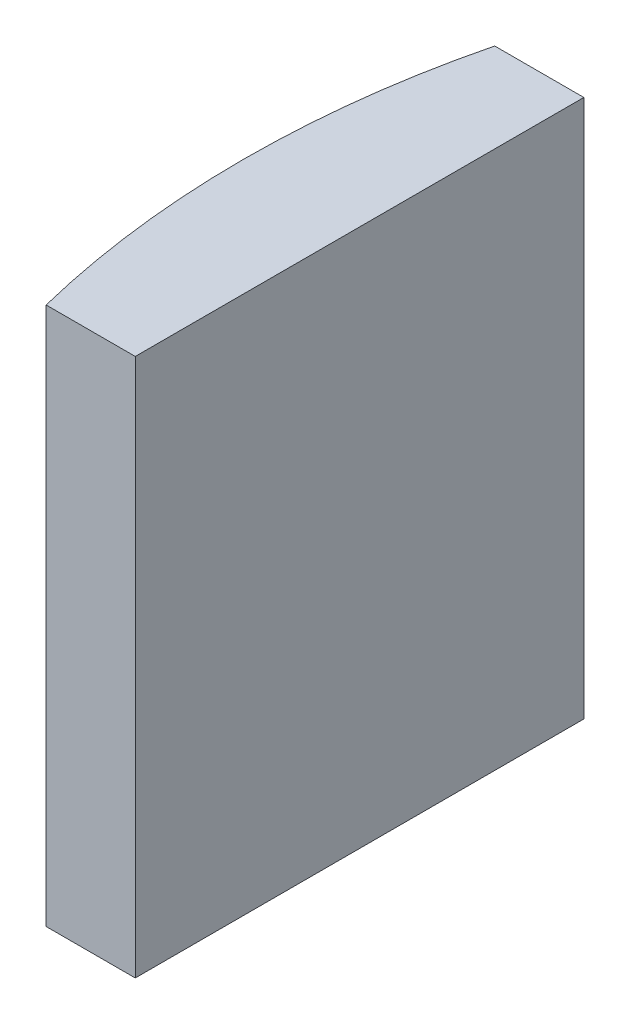
from build123d import *

# Parameters (mm, degrees)
EXTRUDE_1_DEPTH = 12


with BuildPart() as part:
    # 草图1 → 凸台-拉伸1 (new body)
    with BuildSketch(Plane(origin=(0, 0, 0), x_dir=(1, 0, 0), z_dir=(0, 1, 0))):
        with BuildLine():
            Line((-15.711245276, 5), (-13.724795665, 5))
            Line((-13.724795665, 5), (-13.724795665, -5))
            Line((-13.724795665, -5), (-15.711245276, -5))
            ThreePointArc((-15.711245276, -5), (-16.324795665, 0), (-15.711245276, 5))
        make_face()
    extrude(amount=EXTRUDE_1_DEPTH)


solid = part.part
